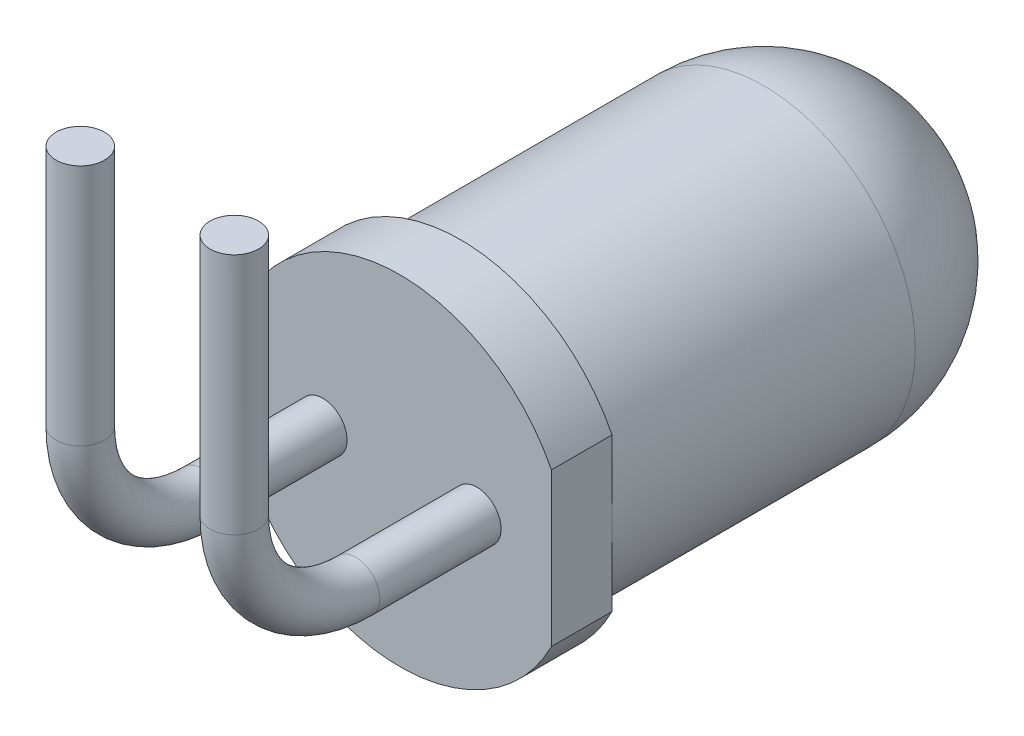
from build123d import *

# Parameters (mm, degrees)
ESQUISSE1_R          = 2.5
BASE_EXTRUSION_DEPTH = 8.5
BOSS_EXTRU_1_DEPTH   = 1
CONG_1_R             = 2.5
ESQUISSE3_R          = 0.4


with BuildPart() as part:
    # Esquisse1 → Base-Extrusion (new body)
    with BuildSketch(Plane.XY):
        Circle(ESQUISSE1_R)
    extrude(amount=BASE_EXTRUSION_DEPTH)

    # Esquisse2 → Boss.-Extru.1 (add)
    with BuildSketch(Plane.XY.offset(8.5)):
        with BuildLine():
            Line((2.5, 1.260952021), (2.5, -1.260952021))
            ThreePointArc((2.5, -1.260952021), (-2.8, 0), (2.5, 1.260952021))
        make_face()
    extrude(amount=-BOSS_EXTRU_1_DEPTH)

    # Congé1
    cong_1_edges = [part.edges().sort_by_distance(p)[0] for p in [
        (-2.5, 0, 0),
    ]]
    fillet(cong_1_edges, radius=CONG_1_R)

    # Balayage1: sweep along a path in Esquisse5
    with BuildLine(Plane(origin=(1.27, 0, 0), x_dir=(0, 0, -1), z_dir=(1, 0, 0))) as balayage1_path:
        Line((-8.5, 0), (-10.5, 0))
        ThreePointArc((-10.5, 0), (-11.914213562, 0.585786438), (-12.5, 2))
        Line((-12.5, 2), (-12.5, 6))
    # Esquisse3 → Balayage1 (sweep)
    with BuildSketch(Plane.XY.offset(8.5)):
        with Locations((1.27, 0)):
            Circle(ESQUISSE3_R)
    balayage1 = sweep(path=balayage1_path.line)

    # Symétrie1: Balayage1 across plane
    add(balayage1.mirror(Plane(origin=(0, 0, 0), x_dir=(0, 0, 1), z_dir=(1, 0, 0))))


solid = part.part
